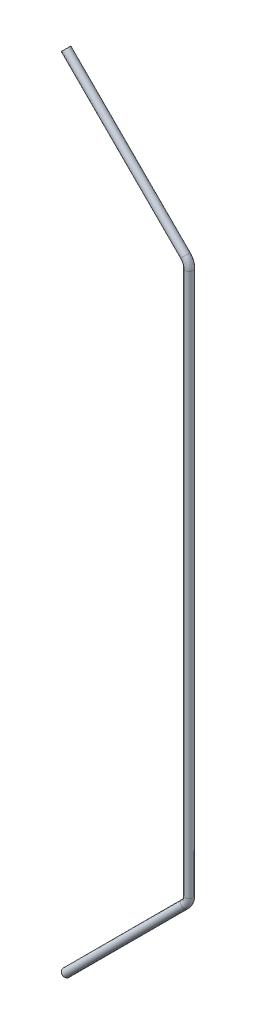
from build123d import *

# Parameters (mm, degrees)
SWEEP_THIN1_PROFILE_R   = 30
SWEEP_THIN1_PROFILE_R_2 = 27


with BuildPart() as part:
    # Sweep-Thin1: sweep along a curve in space
    with BuildLine() as sweep_thin1_path:
        Line((-23026.9467766, 7669.406483062, 40306.600196068), (-22106.735652782, 6749.195359243, 40306.600196068))
        ThreePointArc((-22106.735652782, 6749.195359243, 40306.600196068), (-22085.058377649, 6716.753024361, 40306.600196068), (-22077.4463309, 6678.484681125, 40306.600196068))
        Line((-22077.4463309, 6678.484681125, 40306.600196068), (-22077.4463309, 2489.840786919, 40306.600196068))
        ThreePointArc((-22077.4463309, 2489.840786919, 40306.600196068), (-22085.058377649, 2451.572443682, 40306.600196068), (-22106.735652782, 2419.1301088, 40306.600196068))
        Line((-22106.735652782, 2419.1301088, 40306.600196068), (-23026.9467766, 1498.918984982, 40306.600196068))
    # Sweep-Thin1 profile (on start of the path) → Sweep-Thin1 (sweep)
    with BuildSketch(Plane(origin=(-23026.9467766, 7669.406483062, 40306.600196068), x_dir=(-0.7071067811865492, -0.7071067811865458, 0), z_dir=(0.7071067811865458, -0.7071067811865492, 0))):
        Circle(SWEEP_THIN1_PROFILE_R)
        Circle(SWEEP_THIN1_PROFILE_R_2, mode=Mode.SUBTRACT)
    sweep(path=sweep_thin1_path.line)


solid = part.part
